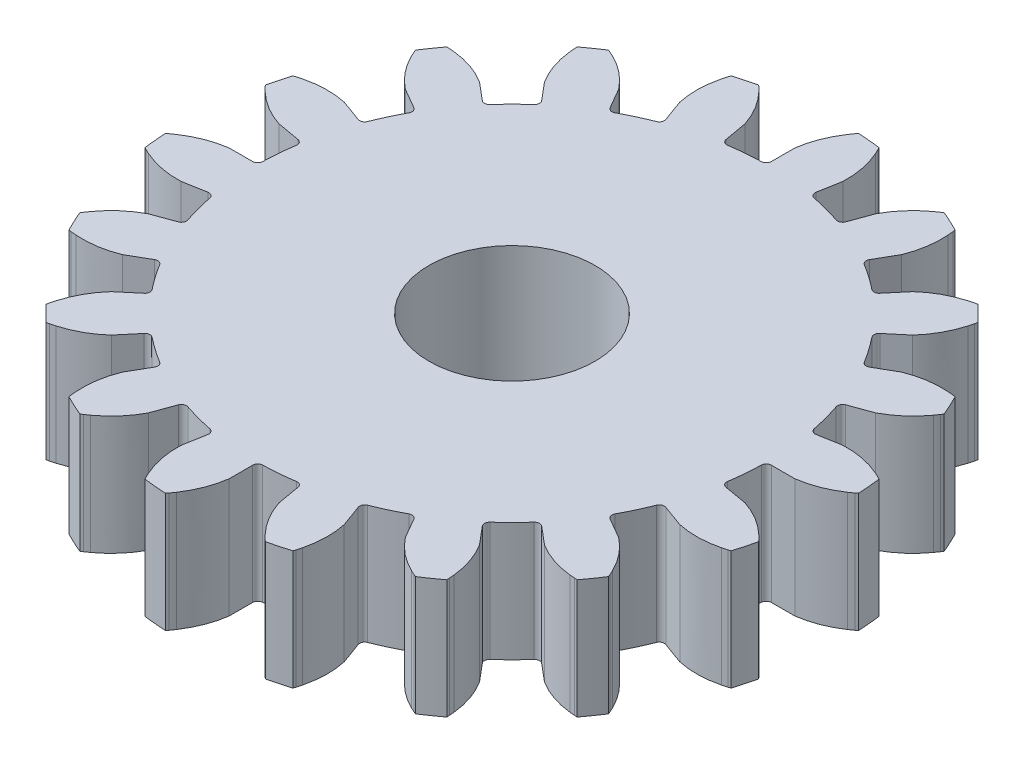
from build123d import *

# Parameters (mm, degrees)
SKETCH1_R           = 4.191
BOSS_EXTRUDE1_DEPTH = 6


with BuildPart() as part:
    # Sketch1 → Boss-Extrude1 (new body)
    with BuildSketch(Plane(origin=(0, 0, 0), x_dir=(1, 0, 0), z_dir=(0, 1, 0))):
        with BuildLine():
            Line((-10.942358242, 9.300717849), (-10.038494718, 8.542286298))
            ThreePointArc((-10.038494718, 8.542286298), (-9.852942621, 8.482425001), (-9.678244592, 8.568990317))
            ThreePointArc((-9.678244592, 8.568990317), (-9.140458009, 9.14046174), (-8.568986367, 9.678248089))
            ThreePointArc((-8.568986367, 9.678248089), (-8.48242098, 9.852946083), (-8.542282201, 10.038498204))
            Line((-8.542282201, 10.038498204), (-9.300713383, 10.942362038))
            add(Edge.make_bspline(
                [(-9.300713383, 10.942362038), (-9.669842677, 11.530599382), (-9.892932785, 12.179785281), (-9.969983707, 12.889919735)],
                knots=[0, 0, 0, 0, 0.823874532, 0.823874532, 0.823874532, 0.823874532], degree=3))
            add(Edge.make_bspline(
                [(-9.969983707, 12.889919735), (-9.980397447, 12.985897255), (-9.987602179, 13.080531207), (-9.991878203, 13.156334226)],
                knots=[0, 0, 0, 0, 0.5, 0.5, 0.5, 0.5], degree=3))
            add(Edge.make_bspline(
                [(-9.991878203, 13.156334226), (-9.996154228, 13.232137244), (-9.997650808, 13.287098421)],
                knots=[0.5, 0.5, 0.5, 1, 1, 1], degree=2))
            ThreePointArc((-9.997650808, 13.287098421), (-9.537592158, 13.621099146), (-9.066384687, 13.939177696))
            add(Edge.make_bspline(
                [(-9.066384687, 13.939177696), (-9.016174727, 13.919361973), (-8.945975013, 13.889241222)],
                knots=[0, 0, 0, 0.5, 0.5, 0.5], degree=2))
            add(Edge.make_bspline(
                [(-8.945975013, 13.889241222), (-8.875775299, 13.85912047), (-8.789091149, 13.819870108), (-8.702621578, 13.777335866)],
                knots=[0.5, 0.5, 0.5, 0.5, 1, 1, 1, 1], degree=3))
            add(Edge.make_bspline(
                [(-8.702621578, 13.777335866), (-8.061666567, 13.462051134), (-7.527932856, 13.030380133), (-7.101420443, 12.482322865)],
                knots=[0.176125468, 0.176125468, 0.176125468, 0.176125468, 1, 1, 1, 1], degree=3))
            Line((-7.101420443, 12.482322865), (-6.511465426, 11.460490801))
            ThreePointArc((-6.511465426, 11.460490801), (-6.357577259, 11.340777027), (-6.163807729, 11.362371571))
            ThreePointArc((-6.163807729, 11.362371571), (-5.462998908, 11.715445206), (-4.742057458, 12.025344257))
            ThreePointArc((-4.742057458, 12.025344257), (-4.600962369, 12.159899566), (-4.593750955, 12.354735269))
            Line((-4.593750955, 12.354735269), (-4.997303501, 13.463488186))
            add(Edge.make_bspline(
                [(-4.997303501, 13.463488186), (-5.142982555, 14.142500131), (-5.130584029, 14.82883664), (-4.960107924, 15.522497714)],
                knots=[0, 0, 0, 0, 0.823874532, 0.823874532, 0.823874532, 0.823874532], degree=3))
            add(Edge.make_bspline(
                [(-4.960107924, 15.522497714), (-4.937067393, 15.61624879), (-4.911470908, 15.70763978), (-4.889562898, 15.780333804)],
                knots=[0, 0, 0, 0, 0.5, 0.5, 0.5, 0.5], degree=3))
            add(Edge.make_bspline(
                [(-4.889562898, 15.780333804), (-4.867654887, 15.853027827), (-4.850263383, 15.9051863)],
                knots=[0.5, 0.5, 0.5, 1, 1, 1], degree=2))
            ThreePointArc((-4.850263383, 15.9051863), (-4.303714689, 16.061694992), (-3.752135234, 16.199428611))
            add(Edge.make_bspline(
                [(-3.752135234, 16.199428611), (-3.711730681, 16.163635104), (-3.656066432, 16.11132114)],
                knots=[0, 0, 0, 0.5, 0.5, 0.5], degree=2))
            add(Edge.make_bspline(
                [(-3.656066432, 16.11132114), (-3.600402182, 16.059007176), (-3.532370141, 15.992476175), (-3.46566289, 15.922932727)],
                knots=[0.5, 0.5, 0.5, 0.5, 1, 1, 1, 1], degree=3))
            add(Edge.make_bspline(
                [(-3.46566289, 15.922932727), (-2.971195926, 15.407442466), (-2.617290474, 14.819256732), (-2.403946532, 14.158375524)],
                knots=[0.176125468, 0.176125468, 0.176125468, 0.176125468, 1, 1, 1, 1], degree=3))
            Line((-2.403946532, 14.158375524), (-2.199057305, 12.996390975))
            ThreePointArc((-2.199057305, 12.996390975), (-2.095394253, 12.831263972), (-1.905924685, 12.785283123))
            ThreePointArc((-1.905924685, 12.785283123), (-1.126621512, 12.877373078), (-0.343166435, 12.922006432))
            ThreePointArc((-0.343166435, 12.922006432), (-0.164559794, 13.000189701), (-0.091145546, 13.180808924))
            Line((-0.091145546, 13.180808924), (-0.091145065, 14.360718958))
            add(Edge.make_bspline(
                [(-0.091145065, 14.360718958), (0.004197166, 15.048606643), (0.250588881, 15.68931145), (0.648030078, 16.282833381)],
                knots=[0, 0, 0, 0, 0.823874532, 0.823874532, 0.823874532, 0.823874532], degree=3))
            add(Edge.make_bspline(
                [(0.648030078, 16.282833381), (0.701745852, 16.36305025), (0.757056239, 16.440175175), (0.802505855, 16.500992232)],
                knots=[0, 0, 0, 0, 0.5, 0.5, 0.5, 0.5], degree=3))
            add(Edge.make_bspline(
                [(0.802505855, 16.500992232), (0.847955471, 16.561809288), (0.882137388, 16.604873976)],
                knots=[0.5, 0.5, 0.5, 1, 1, 1], degree=2))
            ThreePointArc((0.882137388, 16.604873976), (1.449254288, 16.565013376), (2.014677104, 16.505789357))
            add(Edge.make_bspline(
                [(2.014677104, 16.505789357), (2.040402863, 16.458335292), (2.074817718, 16.390137952)],
                knots=[0, 0, 0, 0.5, 0.5, 0.5], degree=2))
            add(Edge.make_bspline(
                [(2.074817718, 16.390137952), (2.109232574, 16.321940611), (2.150406838, 16.236153592), (2.189305889, 16.147988903)],
                knots=[0.5, 0.5, 0.5, 0.5, 1, 1, 1, 1], degree=3))
            add(Edge.make_bspline(
                [(2.189305889, 16.147988903), (2.477644793, 15.494468847), (2.609035767, 14.820712259), (2.583478809, 14.12671914)],
                knots=[0.176125468, 0.176125468, 0.176125468, 0.176125468, 1, 1, 1, 1], degree=3))
            Line((2.583478809, 14.12671914), (2.378589582, 12.96473459))
            ThreePointArc((2.378589582, 12.96473459), (2.419524226, 12.774111112), (2.581841004, 12.666100839))
            ThreePointArc((2.581841004, 12.666100839), (3.345643064, 12.486099708), (4.097115526, 12.260083923))
            ThreePointArc((4.097115526, 12.260083923), (4.29169112, 12.272465095), (4.42245336, 12.417082494))
            Line((4.42245336, 12.417082494), (4.826006811, 13.525835082))
            add(Edge.make_bspline(
                [(4.826006811, 13.525835082), (5.150870647, 14.1396291), (5.601537073, 14.65742375), (6.178006089, 15.079219033)],
                knots=[0, 0, 0, 0, 0.823874532, 0.823874532, 0.823874532, 0.823874532], degree=3))
            add(Edge.make_bspline(
                [(6.178006089, 15.079219033), (6.255918191, 15.136226357), (6.334271231, 15.189782813), (6.397780558, 15.231387468)],
                knots=[0, 0, 0, 0, 0.5, 0.5, 0.5, 0.5], degree=3))
            add(Edge.make_bspline(
                [(6.397780558, 15.231387468), (6.461289886, 15.272992123), (6.508139371, 15.301768789)],
                knots=[0.5, 0.5, 0.5, 1, 1, 1], degree=2))
            ThreePointArc((6.508139371, 15.301768789), (7.027421809, 15.070346673), (7.53848965, 14.821308307))
            add(Edge.make_bspline(
                [(7.53848965, 14.821308307), (7.546433709, 14.767917344), (7.555448231, 14.692062233)],
                knots=[0, 0, 0, 0.5, 0.5, 0.5], degree=2))
            add(Edge.make_bspline(
                [(7.555448231, 14.692062233), (7.564462752, 14.616207122), (7.573813016, 14.521511265), (7.580212068, 14.425359299)],
                knots=[0.5, 0.5, 0.5, 0.5, 1, 1, 1, 1], degree=3))
            add(Edge.make_bspline(
                [(7.580212068, 14.425359299), (7.627644985, 13.712633611), (7.520673789, 13.034571158), (7.259298478, 12.391171939)],
                knots=[0.176125468, 0.176125468, 0.176125468, 0.176125468, 1, 1, 1, 1], degree=3))
            Line((7.259298478, 12.391171939), (6.669343461, 11.369339875))
            ThreePointArc((6.669343461, 11.369339875), (6.642612374, 11.176211927), (6.758198563, 11.019199863))
            ThreePointArc((6.758198563, 11.019199863), (7.414373711, 10.588818438), (8.043224887, 10.119414353))
            ThreePointArc((8.043224887, 10.119414353), (8.230300747, 10.064500077), (8.402639122, 10.15567266))
            Line((8.402639122, 10.15567266), (9.161071042, 11.059535875))
            add(Edge.make_bspline(
                [(9.161071042, 11.059535875), (9.676273109, 11.525203609), (10.276857224, 11.857634425), (10.962823388, 12.056828325)],
                knots=[0, 0, 0, 0, 0.823874532, 0.823874532, 0.823874532, 0.823874532], degree=3))
            add(Edge.make_bspline(
                [(10.962823388, 12.056828325), (11.055534468, 12.083750178), (11.147479629, 12.107278467), (11.221388505, 12.124652585)],
                knots=[0, 0, 0, 0, 0.5, 0.5, 0.5, 0.5], degree=3))
            add(Edge.make_bspline(
                [(11.221388505, 12.124652585), (11.295297381, 12.142026703), (11.349163696, 12.153044455)],
                knots=[0.5, 0.5, 0.5, 1, 1, 1], degree=2))
            ThreePointArc((11.349163696, 12.153044455), (11.757978546, 11.757973747), (12.153049087, 11.349158736))
            add(Edge.make_bspline(
                [(12.153049087, 11.349158736), (12.142253277, 11.296270614), (12.12478018, 11.221906978)],
                knots=[0, 0, 0, 0.5, 0.5, 0.5], degree=2))
            add(Edge.make_bspline(
                [(12.12478018, 11.221906978), (12.107307083, 11.147543342), (12.083705567, 11.055360365), (12.056832799, 10.962818467)],
                knots=[0.5, 0.5, 0.5, 0.5, 1, 1, 1, 1], degree=3))
            add(Edge.make_bspline(
                [(12.056832799, 10.962818467), (11.85763862, 10.276852385), (11.525207558, 9.676268405), (11.059539614, 9.161066528)],
                knots=[0.176125468, 0.176125468, 0.176125468, 0.176125468, 1, 1, 1, 1], degree=3))
            Line((11.059539614, 9.161066528), (10.155676089, 8.402634978))
            ThreePointArc((10.155676089, 8.402634978), (10.064503436, 8.23029664), (10.119417636, 8.043220757))
            ThreePointArc((10.119417636, 8.043220757), (10.588821464, 7.414369389), (11.019202621, 6.758194066))
            ThreePointArc((11.019202621, 6.758194066), (11.176214638, 6.642607813), (11.369342597, 6.669338821))
            Line((11.369342597, 6.669338821), (12.391174902, 7.259293421))
            add(Edge.make_bspline(
                [(12.391174902, 7.259293421), (13.034574227, 7.520668469), (13.712636724, 7.627639389), (14.425362393, 7.58020618)],
                knots=[0, 0, 0, 0, 0.823874532, 0.823874532, 0.823874532, 0.823874532], degree=3))
            add(Edge.make_bspline(
                [(14.425362393, 7.58020618), (14.521690126, 7.57379539), (14.616137464, 7.564457653), (14.691531388, 7.555505659)],
                knots=[0, 0, 0, 0, 0.5, 0.5, 0.5, 0.5], degree=3))
            add(Edge.make_bspline(
                [(14.691531388, 7.555505659), (14.766925312, 7.546553665), (14.821311384, 7.538483601)],
                knots=[0.5, 0.5, 0.5, 1, 1, 1], degree=2))
            ThreePointArc((14.821311384, 7.538483601), (15.070349541, 7.027415658), (15.301771445, 6.508133126))
            add(Edge.make_bspline(
                [(15.301771445, 6.508133126), (15.273537898, 6.462126932), (15.231684697, 6.398224123)],
                knots=[0, 0, 0, 0.5, 0.5, 0.5], degree=2))
            add(Edge.make_bspline(
                [(15.231684697, 6.398224123), (15.189831495, 6.334321314), (15.13612489, 6.255769845), (15.079221555, 6.177999935)],
                knots=[0.5, 0.5, 0.5, 0.5, 1, 1, 1, 1], degree=3))
            add(Edge.make_bspline(
                [(15.079221555, 6.177999935), (14.657426036, 5.601531091), (14.139631202, 5.150864876), (13.525837052, 4.826001291)],
                knots=[0.176125468, 0.176125468, 0.176125468, 0.176125468, 1, 1, 1, 1], degree=3))
            Line((13.525837052, 4.826001291), (12.417084299, 4.422448292))
            ThreePointArc((12.417084299, 4.422448292), (12.272466847, 4.291686111), (12.260085595, 4.097110522))
            ThreePointArc((12.260085595, 4.097110522), (12.486101074, 3.345637968), (12.666101893, 2.581835834))
            ThreePointArc((12.666101893, 2.581835834), (12.7741121, 2.419519012), (12.964735561, 2.378584291))
            Line((12.964735561, 2.378584291), (14.126720194, 2.583473044))
            add(Edge.make_bspline(
                [(14.126720194, 2.583473044), (14.820713324, 2.609029718), (15.494469858, 2.47763847), (16.147989797, 2.189299299)],
                knots=[0, 0, 0, 0, 0.823874532, 0.823874532, 0.823874532, 0.823874532], degree=3))
            add(Edge.make_bspline(
                [(16.147989797, 2.189299299), (16.236315638, 2.150329101), (16.32187341, 2.109251606), (16.389658762, 2.075053243)],
                knots=[0, 0, 0, 0, 0.5, 0.5, 0.5, 0.5], degree=3))
            add(Edge.make_bspline(
                [(16.389658762, 2.075053243), (16.457444113, 2.040854879), (16.505790179, 2.014670368)],
                knots=[0.5, 0.5, 0.5, 1, 1, 1], degree=2))
            ThreePointArc((16.505790179, 2.014670368), (16.565013967, 1.449247527), (16.604874336, 0.882130611))
            add(Edge.make_bspline(
                [(16.604874336, 0.882130611), (16.562608436, 0.848555372), (16.501423243, 0.802821012)],
                knots=[0, 0, 0, 0.5, 0.5, 0.5], degree=2))
            add(Edge.make_bspline(
                [(16.501423243, 0.802821012), (16.440238051, 0.757086652), (16.362904165, 0.701641157), (16.282833645, 0.648023433)],
                knots=[0.5, 0.5, 0.5, 0.5, 1, 1, 1, 1], degree=3))
            add(Edge.make_bspline(
                [(16.282833645, 0.648023433), (15.689311553, 0.250582477), (15.048606644, 0.004191024), (14.360718921, -0.091150926)],
                knots=[0.176125468, 0.176125468, 0.176125468, 0.176125468, 1, 1, 1, 1], degree=3))
            Line((14.360718921, -0.091150926), (13.180808887, -0.091150926))
            ThreePointArc((13.180808887, -0.091150926), (13.000189634, -0.1645651), (12.922006292, -0.343171709))
            ThreePointArc((12.922006292, -0.343171709), (12.877372619, -1.126626768), (12.785282345, -1.905929903))
            ThreePointArc((12.785282345, -1.905929903), (12.831263117, -2.095399489), (12.996390077, -2.199062609))
            Line((12.996390077, -2.199062609), (14.158374543, -2.40395231))
            add(Edge.make_bspline(
                [(14.158374543, -2.40395231), (14.819255663, -2.617296522), (15.407441253, -2.971202215), (15.922931312, -3.465669389)],
                knots=[0, 0, 0, 0, 0.823874532, 0.823874532, 0.823874532, 0.823874532], degree=3))
            add(Edge.make_bspline(
                [(15.922931312, -3.465669389), (15.992601861, -3.532498613), (16.058950537, -3.600361313), (16.110951403, -3.655681219)],
                knots=[0, 0, 0, 0, 0.5, 0.5, 0.5, 0.5], degree=3))
            add(Edge.make_bspline(
                [(16.110951403, -3.655681219), (16.162952269, -3.711001124), (16.19942708, -3.752141845)],
                knots=[0.5, 0.5, 0.5, 1, 1, 1], degree=2))
            ThreePointArc((16.19942708, -3.752141845), (16.061693235, -4.303721244), (15.905184321, -4.850269875))
            add(Edge.make_bspline(
                [(15.905184321, -4.850269875), (15.853983958, -4.86736449), (15.780846612, -4.889414162)],
                knots=[0, 0, 0, 0.5, 0.5, 0.5], degree=2))
            add(Edge.make_bspline(
                [(15.780846612, -4.889414162), (15.707709266, -4.911463835), (15.616075708, -4.93711581), (15.522495689, -4.960114259)],
                knots=[0.5, 0.5, 0.5, 0.5, 1, 1, 1, 1], degree=3))
            add(Edge.make_bspline(
                [(15.522495689, -4.960114259), (14.828834546, -5.130590081), (14.142498032, -5.142988327), (13.463486146, -4.997308996)],
                knots=[0.176125468, 0.176125468, 0.176125468, 0.176125468, 1, 1, 1, 1], degree=3))
            Line((13.463486146, -4.997308996), (12.354733394, -4.593755997))
            ThreePointArc((12.354733394, -4.593755997), (12.159897689, -4.600967332), (12.025342321, -4.742062366))
            ThreePointArc((12.025342321, -4.742062366), (11.715442976, -5.463003689), (11.362369055, -6.163812366))
            ThreePointArc((11.362369055, -6.163812366), (11.340774432, -6.357581888), (11.460488144, -6.511470103))
            Line((11.460488144, -6.511470103), (12.482319967, -7.101425537))
            add(Edge.make_bspline(
                [(12.482319967, -7.101425537), (13.030377061, -7.527938174), (13.462047844, -8.061672062), (13.777332314, -8.702627201)],
                knots=[0, 0, 0, 0, 0.823874532, 0.823874532, 0.823874532, 0.823874532], degree=3))
            add(Edge.make_bspline(
                [(13.777332314, -8.702627201), (13.819944274, -8.78925486), (13.859081225, -8.875717523), (13.889025533, -8.945486573)],
                knots=[0, 0, 0, 0, 0.5, 0.5, 0.5, 0.5], degree=3))
            add(Edge.make_bspline(
                [(13.889025533, -8.945486573), (13.918969841, -9.015255624), (13.939173996, -9.066390376)],
                knots=[0.5, 0.5, 0.5, 1, 1, 1], degree=2))
            ThreePointArc((13.939173996, -9.066390376), (13.621095254, -9.537597718), (13.287094341, -9.997656231))
            add(Edge.make_bspline(
                [(13.287094341, -9.997656231), (13.233135035, -9.996208359), (13.156866978, -9.991913828)],
                knots=[0, 0, 0, 0.5, 0.5, 0.5], degree=2))
            add(Edge.make_bspline(
                [(13.156866978, -9.991913828), (13.080598922, -9.987619297), (12.985718051, -9.980383747), (12.889915666, -9.969988968)],
                knots=[0.5, 0.5, 0.5, 0.5, 1, 1, 1, 1], degree=3))
            add(Edge.make_bspline(
                [(12.889915666, -9.969988968), (12.179781243, -9.892937756), (11.530595435, -9.669847383), (10.942358242, -9.300717849)],
                knots=[0.176125468, 0.176125468, 0.176125468, 0.176125468, 1, 1, 1, 1], degree=3))
            Line((10.942358242, -9.300717849), (10.038494718, -8.542286298))
            ThreePointArc((10.038494718, -8.542286298), (9.852942621, -8.482425001), (9.678244592, -8.568990317))
            ThreePointArc((9.678244592, -8.568990317), (9.140458009, -9.14046174), (8.568986367, -9.678248089))
            ThreePointArc((8.568986367, -9.678248089), (8.48242098, -9.852946083), (8.542282201, -10.038498204))
            Line((8.542282201, -10.038498204), (9.300713383, -10.942362038))
            add(Edge.make_bspline(
                [(9.300713383, -10.942362038), (9.669842677, -11.530599382), (9.892932785, -12.179785281), (9.969983707, -12.889919735)],
                knots=[0, 0, 0, 0, 0.823874532, 0.823874532, 0.823874532, 0.823874532], degree=3))
            add(Edge.make_bspline(
                [(9.969983707, -12.889919735), (9.980397447, -12.985897255), (9.987602179, -13.080531207), (9.991878203, -13.156334226)],
                knots=[0, 0, 0, 0, 0.5, 0.5, 0.5, 0.5], degree=3))
            add(Edge.make_bspline(
                [(9.991878203, -13.156334226), (9.996154228, -13.232137244), (9.997650808, -13.287098421)],
                knots=[0.5, 0.5, 0.5, 1, 1, 1], degree=2))
            ThreePointArc((9.997650808, -13.287098421), (9.537592158, -13.621099146), (9.066384687, -13.939177696))
            add(Edge.make_bspline(
                [(9.066384687, -13.939177696), (9.016174727, -13.919361973), (8.945975013, -13.889241222)],
                knots=[0, 0, 0, 0.5, 0.5, 0.5], degree=2))
            add(Edge.make_bspline(
                [(8.945975013, -13.889241222), (8.875775299, -13.85912047), (8.789091149, -13.819870108), (8.702621578, -13.777335866)],
                knots=[0.5, 0.5, 0.5, 0.5, 1, 1, 1, 1], degree=3))
            add(Edge.make_bspline(
                [(8.702621578, -13.777335866), (8.061666567, -13.462051134), (7.527932856, -13.030380133), (7.101420443, -12.482322865)],
                knots=[0.176125468, 0.176125468, 0.176125468, 0.176125468, 1, 1, 1, 1], degree=3))
            Line((7.101420443, -12.482322865), (6.511465426, -11.460490801))
            ThreePointArc((6.511465426, -11.460490801), (6.357577259, -11.340777027), (6.163807729, -11.362371571))
            ThreePointArc((6.163807729, -11.362371571), (5.462998908, -11.715445206), (4.742057458, -12.025344257))
            ThreePointArc((4.742057458, -12.025344257), (4.600962369, -12.159899566), (4.593750955, -12.354735269))
            Line((4.593750955, -12.354735269), (4.997303501, -13.463488186))
            add(Edge.make_bspline(
                [(4.997303501, -13.463488186), (5.142982555, -14.142500131), (5.130584029, -14.82883664), (4.960107924, -15.522497714)],
                knots=[0, 0, 0, 0, 0.823874532, 0.823874532, 0.823874532, 0.823874532], degree=3))
            add(Edge.make_bspline(
                [(4.960107924, -15.522497714), (4.937067393, -15.61624879), (4.911470908, -15.70763978), (4.889562898, -15.780333804)],
                knots=[0, 0, 0, 0, 0.5, 0.5, 0.5, 0.5], degree=3))
            add(Edge.make_bspline(
                [(4.889562898, -15.780333804), (4.867654887, -15.853027827), (4.850263383, -15.9051863)],
                knots=[0.5, 0.5, 0.5, 1, 1, 1], degree=2))
            ThreePointArc((4.850263383, -15.9051863), (4.303714689, -16.061694992), (3.752135234, -16.199428611))
            add(Edge.make_bspline(
                [(3.752135234, -16.199428611), (3.711730681, -16.163635104), (3.656066432, -16.11132114)],
                knots=[0, 0, 0, 0.5, 0.5, 0.5], degree=2))
            add(Edge.make_bspline(
                [(3.656066432, -16.11132114), (3.600402182, -16.059007176), (3.532370141, -15.992476175), (3.46566289, -15.922932727)],
                knots=[0.5, 0.5, 0.5, 0.5, 1, 1, 1, 1], degree=3))
            add(Edge.make_bspline(
                [(3.46566289, -15.922932727), (2.971195926, -15.407442466), (2.617290474, -14.819256732), (2.403946532, -14.158375524)],
                knots=[0.176125468, 0.176125468, 0.176125468, 0.176125468, 1, 1, 1, 1], degree=3))
            Line((2.403946532, -14.158375524), (2.199057305, -12.996390975))
            ThreePointArc((2.199057305, -12.996390975), (2.095394253, -12.831263972), (1.905924685, -12.785283123))
            ThreePointArc((1.905924685, -12.785283123), (1.126621512, -12.877373078), (0.343166435, -12.922006432))
            ThreePointArc((0.343166435, -12.922006432), (0.164559794, -13.000189701), (0.091145546, -13.180808924))
            Line((0.091145546, -13.180808924), (0.091145065, -14.360718958))
            add(Edge.make_bspline(
                [(0.091145065, -14.360718958), (-0.004197166, -15.048606643), (-0.250588881, -15.68931145), (-0.648030078, -16.282833381)],
                knots=[0, 0, 0, 0, 0.823874532, 0.823874532, 0.823874532, 0.823874532], degree=3))
            add(Edge.make_bspline(
                [(-0.648030078, -16.282833381), (-0.701745852, -16.36305025), (-0.757056239, -16.440175175), (-0.802505855, -16.500992232)],
                knots=[0, 0, 0, 0, 0.5, 0.5, 0.5, 0.5], degree=3))
            add(Edge.make_bspline(
                [(-0.802505855, -16.500992232), (-0.847955471, -16.561809288), (-0.882137388, -16.604873976)],
                knots=[0.5, 0.5, 0.5, 1, 1, 1], degree=2))
            ThreePointArc((-0.882137388, -16.604873976), (-1.449254288, -16.565013376), (-2.014677104, -16.505789357))
            add(Edge.make_bspline(
                [(-2.014677104, -16.505789357), (-2.040402863, -16.458335292), (-2.074817718, -16.390137952)],
                knots=[0, 0, 0, 0.5, 0.5, 0.5], degree=2))
            add(Edge.make_bspline(
                [(-2.074817718, -16.390137952), (-2.109232574, -16.321940611), (-2.150406838, -16.236153592), (-2.189305889, -16.147988903)],
                knots=[0.5, 0.5, 0.5, 0.5, 1, 1, 1, 1], degree=3))
            add(Edge.make_bspline(
                [(-2.189305889, -16.147988903), (-2.477644793, -15.494468847), (-2.609035767, -14.820712259), (-2.583478809, -14.12671914)],
                knots=[0.176125468, 0.176125468, 0.176125468, 0.176125468, 1, 1, 1, 1], degree=3))
            Line((-2.583478809, -14.12671914), (-2.378589582, -12.96473459))
            ThreePointArc((-2.378589582, -12.96473459), (-2.419524226, -12.774111112), (-2.581841004, -12.666100839))
            ThreePointArc((-2.581841004, -12.666100839), (-3.345643064, -12.486099708), (-4.097115526, -12.260083923))
            ThreePointArc((-4.097115526, -12.260083923), (-4.29169112, -12.272465095), (-4.42245336, -12.417082494))
            Line((-4.42245336, -12.417082494), (-4.826006811, -13.525835082))
            add(Edge.make_bspline(
                [(-4.826006811, -13.525835082), (-5.150870647, -14.1396291), (-5.601537073, -14.65742375), (-6.178006089, -15.079219033)],
                knots=[0, 0, 0, 0, 0.823874532, 0.823874532, 0.823874532, 0.823874532], degree=3))
            add(Edge.make_bspline(
                [(-6.178006089, -15.079219033), (-6.255918191, -15.136226357), (-6.334271231, -15.189782813), (-6.397780558, -15.231387468)],
                knots=[0, 0, 0, 0, 0.5, 0.5, 0.5, 0.5], degree=3))
            add(Edge.make_bspline(
                [(-6.397780558, -15.231387468), (-6.461289886, -15.272992123), (-6.508139371, -15.301768789)],
                knots=[0.5, 0.5, 0.5, 1, 1, 1], degree=2))
            ThreePointArc((-6.508139371, -15.301768789), (-7.027421809, -15.070346673), (-7.53848965, -14.821308307))
            add(Edge.make_bspline(
                [(-7.53848965, -14.821308307), (-7.546433709, -14.767917344), (-7.555448231, -14.692062233)],
                knots=[0, 0, 0, 0.5, 0.5, 0.5], degree=2))
            add(Edge.make_bspline(
                [(-7.555448231, -14.692062233), (-7.564462752, -14.616207122), (-7.573813016, -14.521511265), (-7.580212068, -14.425359299)],
                knots=[0.5, 0.5, 0.5, 0.5, 1, 1, 1, 1], degree=3))
            add(Edge.make_bspline(
                [(-7.580212068, -14.425359299), (-7.627644985, -13.712633611), (-7.520673789, -13.034571158), (-7.259298478, -12.391171939)],
                knots=[0.176125468, 0.176125468, 0.176125468, 0.176125468, 1, 1, 1, 1], degree=3))
            Line((-7.259298478, -12.391171939), (-6.669343461, -11.369339875))
            ThreePointArc((-6.669343461, -11.369339875), (-6.642612374, -11.176211927), (-6.758198563, -11.019199863))
            ThreePointArc((-6.758198563, -11.019199863), (-7.414373711, -10.588818438), (-8.043224887, -10.119414353))
            ThreePointArc((-8.043224887, -10.119414353), (-8.230300747, -10.064500077), (-8.402639122, -10.15567266))
            Line((-8.402639122, -10.15567266), (-9.161071042, -11.059535875))
            add(Edge.make_bspline(
                [(-9.161071042, -11.059535875), (-9.676273109, -11.525203609), (-10.276857224, -11.857634425), (-10.962823388, -12.056828325)],
                knots=[0, 0, 0, 0, 0.823874532, 0.823874532, 0.823874532, 0.823874532], degree=3))
            add(Edge.make_bspline(
                [(-10.962823388, -12.056828325), (-11.055534468, -12.083750178), (-11.147479629, -12.107278467), (-11.221388505, -12.124652585)],
                knots=[0, 0, 0, 0, 0.5, 0.5, 0.5, 0.5], degree=3))
            add(Edge.make_bspline(
                [(-11.221388505, -12.124652585), (-11.295297381, -12.142026703), (-11.349163696, -12.153044455)],
                knots=[0.5, 0.5, 0.5, 1, 1, 1], degree=2))
            ThreePointArc((-11.349163696, -12.153044455), (-11.757978546, -11.757973747), (-12.153049087, -11.349158736))
            add(Edge.make_bspline(
                [(-12.153049087, -11.349158736), (-12.142253277, -11.296270614), (-12.12478018, -11.221906978)],
                knots=[0, 0, 0, 0.5, 0.5, 0.5], degree=2))
            add(Edge.make_bspline(
                [(-12.12478018, -11.221906978), (-12.107307083, -11.147543342), (-12.083705567, -11.055360365), (-12.056832799, -10.962818467)],
                knots=[0.5, 0.5, 0.5, 0.5, 1, 1, 1, 1], degree=3))
            add(Edge.make_bspline(
                [(-12.056832799, -10.962818467), (-11.85763862, -10.276852385), (-11.525207558, -9.676268405), (-11.059539614, -9.161066528)],
                knots=[0.176125468, 0.176125468, 0.176125468, 0.176125468, 1, 1, 1, 1], degree=3))
            Line((-11.059539614, -9.161066528), (-10.155676089, -8.402634978))
            ThreePointArc((-10.155676089, -8.402634978), (-10.064503436, -8.23029664), (-10.119417636, -8.043220757))
            ThreePointArc((-10.119417636, -8.043220757), (-10.588821464, -7.414369389), (-11.019202621, -6.758194066))
            ThreePointArc((-11.019202621, -6.758194066), (-11.176214638, -6.642607813), (-11.369342597, -6.669338821))
            Line((-11.369342597, -6.669338821), (-12.391174902, -7.259293421))
            add(Edge.make_bspline(
                [(-12.391174902, -7.259293421), (-13.034574227, -7.520668469), (-13.712636724, -7.627639389), (-14.425362392, -7.58020618)],
                knots=[0, 0, 0, 0, 0.823874532, 0.823874532, 0.823874532, 0.823874532], degree=3))
            add(Edge.make_bspline(
                [(-14.425362392, -7.58020618), (-14.521690126, -7.57379539), (-14.616137464, -7.564457653), (-14.691531388, -7.555505659)],
                knots=[0, 0, 0, 0, 0.5, 0.5, 0.5, 0.5], degree=3))
            add(Edge.make_bspline(
                [(-14.691531388, -7.555505659), (-14.766925312, -7.546553665), (-14.821311384, -7.538483601)],
                knots=[0.5, 0.5, 0.5, 1, 1, 1], degree=2))
            ThreePointArc((-14.821311384, -7.538483601), (-15.070349541, -7.027415658), (-15.301771445, -6.508133126))
            add(Edge.make_bspline(
                [(-15.301771445, -6.508133126), (-15.273537898, -6.462126932), (-15.231684697, -6.398224123)],
                knots=[0, 0, 0, 0.5, 0.5, 0.5], degree=2))
            add(Edge.make_bspline(
                [(-15.231684697, -6.398224123), (-15.189831495, -6.334321314), (-15.13612489, -6.255769845), (-15.079221555, -6.177999935)],
                knots=[0.5, 0.5, 0.5, 0.5, 1, 1, 1, 1], degree=3))
            add(Edge.make_bspline(
                [(-15.079221555, -6.177999935), (-14.657426036, -5.601531091), (-14.139631202, -5.150864876), (-13.525837052, -4.826001291)],
                knots=[0.176125468, 0.176125468, 0.176125468, 0.176125468, 1, 1, 1, 1], degree=3))
            Line((-13.525837052, -4.826001291), (-12.417084299, -4.422448292))
            ThreePointArc((-12.417084299, -4.422448292), (-12.272466847, -4.291686111), (-12.260085595, -4.097110522))
            ThreePointArc((-12.260085595, -4.097110522), (-12.486101074, -3.345637968), (-12.666101893, -2.581835834))
            ThreePointArc((-12.666101893, -2.581835834), (-12.7741121, -2.419519012), (-12.964735561, -2.378584291))
            Line((-12.964735561, -2.378584291), (-14.126720194, -2.583473044))
            add(Edge.make_bspline(
                [(-14.126720194, -2.583473044), (-14.820713324, -2.609029718), (-15.494469858, -2.47763847), (-16.147989797, -2.189299299)],
                knots=[0, 0, 0, 0, 0.823874532, 0.823874532, 0.823874532, 0.823874532], degree=3))
            add(Edge.make_bspline(
                [(-16.147989797, -2.189299299), (-16.236315638, -2.150329101), (-16.32187341, -2.109251606), (-16.389658762, -2.075053243)],
                knots=[0, 0, 0, 0, 0.5, 0.5, 0.5, 0.5], degree=3))
            add(Edge.make_bspline(
                [(-16.389658762, -2.075053243), (-16.457444113, -2.040854879), (-16.505790179, -2.014670368)],
                knots=[0.5, 0.5, 0.5, 1, 1, 1], degree=2))
            ThreePointArc((-16.505790179, -2.014670368), (-16.565013967, -1.449247527), (-16.604874336, -0.882130611))
            add(Edge.make_bspline(
                [(-16.604874336, -0.882130611), (-16.562608436, -0.848555372), (-16.501423243, -0.802821012)],
                knots=[0, 0, 0, 0.5, 0.5, 0.5], degree=2))
            add(Edge.make_bspline(
                [(-16.501423243, -0.802821012), (-16.440238051, -0.757086652), (-16.362904165, -0.701641157), (-16.282833645, -0.648023433)],
                knots=[0.5, 0.5, 0.5, 0.5, 1, 1, 1, 1], degree=3))
            add(Edge.make_bspline(
                [(-16.282833645, -0.648023433), (-15.689311553, -0.250582477), (-15.048606644, -0.004191024), (-14.360718921, 0.091150926)],
                knots=[0.176125468, 0.176125468, 0.176125468, 0.176125468, 1, 1, 1, 1], degree=3))
            Line((-14.360718921, 0.091150926), (-13.180808887, 0.091150926))
            ThreePointArc((-13.180808887, 0.091150926), (-13.000189634, 0.1645651), (-12.922006292, 0.343171709))
            ThreePointArc((-12.922006292, 0.343171709), (-12.877372619, 1.126626768), (-12.785282345, 1.905929903))
            ThreePointArc((-12.785282345, 1.905929903), (-12.831263117, 2.095399489), (-12.996390077, 2.199062609))
            Line((-12.996390077, 2.199062609), (-14.158374543, 2.40395231))
            add(Edge.make_bspline(
                [(-14.158374543, 2.40395231), (-14.819255663, 2.617296522), (-15.407441253, 2.971202215), (-15.922931312, 3.465669389)],
                knots=[0, 0, 0, 0, 0.823874532, 0.823874532, 0.823874532, 0.823874532], degree=3))
            add(Edge.make_bspline(
                [(-15.922931312, 3.465669389), (-15.992601861, 3.532498613), (-16.058950537, 3.600361313), (-16.110951403, 3.655681219)],
                knots=[0, 0, 0, 0, 0.5, 0.5, 0.5, 0.5], degree=3))
            add(Edge.make_bspline(
                [(-16.110951403, 3.655681219), (-16.162952269, 3.711001124), (-16.19942708, 3.752141845)],
                knots=[0.5, 0.5, 0.5, 1, 1, 1], degree=2))
            ThreePointArc((-16.19942708, 3.752141845), (-16.061693235, 4.303721244), (-15.905184321, 4.850269875))
            add(Edge.make_bspline(
                [(-15.905184321, 4.850269875), (-15.853983958, 4.86736449), (-15.780846612, 4.889414162)],
                knots=[0, 0, 0, 0.5, 0.5, 0.5], degree=2))
            add(Edge.make_bspline(
                [(-15.780846612, 4.889414162), (-15.707709266, 4.911463835), (-15.616075708, 4.93711581), (-15.522495689, 4.960114259)],
                knots=[0.5, 0.5, 0.5, 0.5, 1, 1, 1, 1], degree=3))
            add(Edge.make_bspline(
                [(-15.522495689, 4.960114259), (-14.828834546, 5.130590081), (-14.142498032, 5.142988327), (-13.463486146, 4.997308996)],
                knots=[0.176125468, 0.176125468, 0.176125468, 0.176125468, 1, 1, 1, 1], degree=3))
            Line((-13.463486146, 4.997308996), (-12.354733394, 4.593755997))
            ThreePointArc((-12.354733394, 4.593755997), (-12.159897689, 4.600967332), (-12.025342321, 4.742062366))
            ThreePointArc((-12.025342321, 4.742062366), (-11.715442976, 5.463003689), (-11.362369055, 6.163812366))
            ThreePointArc((-11.362369055, 6.163812366), (-11.340774432, 6.357581888), (-11.460488144, 6.511470103))
            Line((-11.460488144, 6.511470103), (-12.482319967, 7.101425537))
            add(Edge.make_bspline(
                [(-12.482319967, 7.101425537), (-13.030377061, 7.527938174), (-13.462047844, 8.061672062), (-13.777332314, 8.702627201)],
                knots=[0, 0, 0, 0, 0.823874532, 0.823874532, 0.823874532, 0.823874532], degree=3))
            add(Edge.make_bspline(
                [(-13.777332314, 8.702627201), (-13.819944274, 8.78925486), (-13.859081225, 8.875717523), (-13.889025533, 8.945486573)],
                knots=[0, 0, 0, 0, 0.5, 0.5, 0.5, 0.5], degree=3))
            add(Edge.make_bspline(
                [(-13.889025533, 8.945486573), (-13.918969841, 9.015255624), (-13.939173996, 9.066390376)],
                knots=[0.5, 0.5, 0.5, 1, 1, 1], degree=2))
            ThreePointArc((-13.939173996, 9.066390376), (-13.621095254, 9.537597718), (-13.287094341, 9.997656231))
            add(Edge.make_bspline(
                [(-13.287094341, 9.997656231), (-13.233135035, 9.996208359), (-13.156866978, 9.991913828)],
                knots=[0, 0, 0, 0.5, 0.5, 0.5], degree=2))
            add(Edge.make_bspline(
                [(-13.156866978, 9.991913828), (-13.080598922, 9.987619297), (-12.985718051, 9.980383747), (-12.889915666, 9.969988968)],
                knots=[0.5, 0.5, 0.5, 0.5, 1, 1, 1, 1], degree=3))
            add(Edge.make_bspline(
                [(-12.889915666, 9.969988968), (-12.179781243, 9.892937756), (-11.530595435, 9.669847383), (-10.942358242, 9.300717849)],
                knots=[0.176125468, 0.176125468, 0.176125468, 0.176125468, 1, 1, 1, 1], degree=3))
        make_face()
        Circle(SKETCH1_R, mode=Mode.SUBTRACT)
    extrude(amount=BOSS_EXTRUDE1_DEPTH)


solid = part.part
